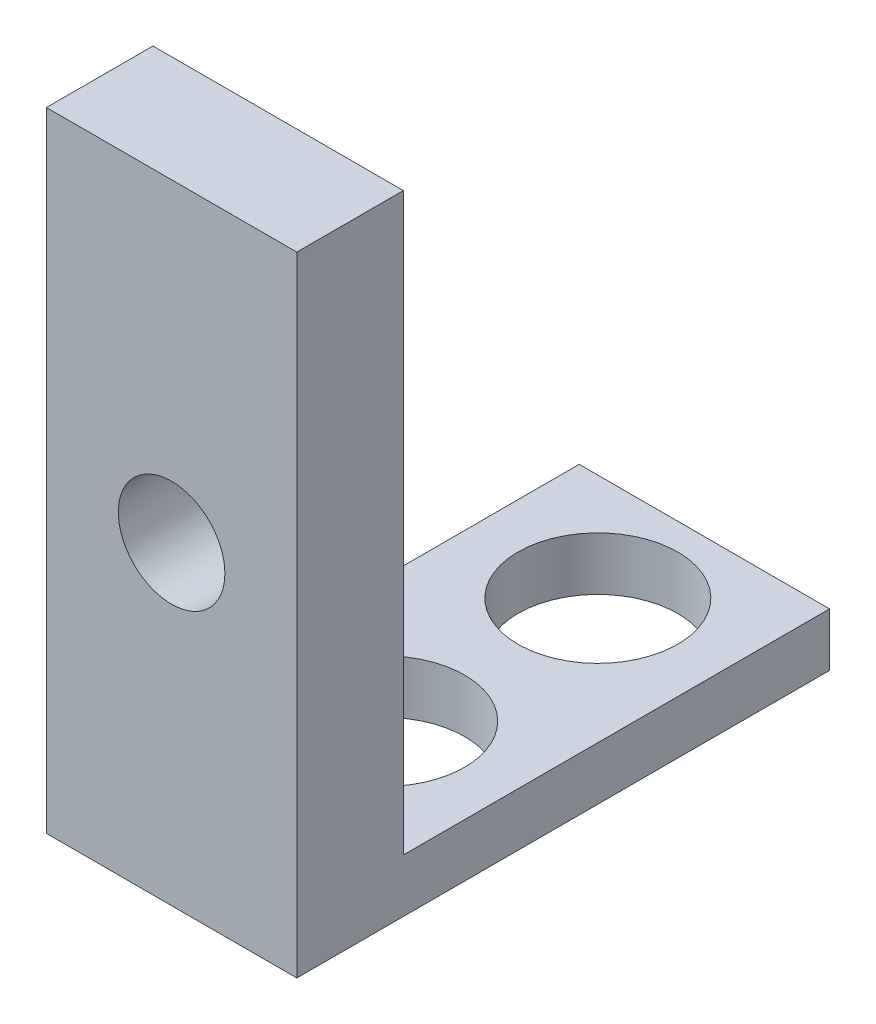
from build123d import *

# Parameters (mm, degrees)
SKETCH1_W           = 4.7
SKETCH1_H           = 11.8
SKETCH1_R           = 1
BOSS_EXTRUDE1_DEPTH = 2
SKETCH2_W           = 4.7
SKETCH2_H           = 1
BOSS_EXTRUDE2_DEPTH = 8
SKETCH3_R           = 1.5
CUT_EXTRUDE1_DEPTH  = 8


with BuildPart() as part:
    # Sketch1 → Boss-Extrude1 (new body)
    with BuildSketch(Plane.XY):
        with Locations((2.35, 5.9)):
            Rectangle(SKETCH1_W, SKETCH1_H)
        with Locations((2.35, 5.9)):
            Circle(SKETCH1_R, mode=Mode.SUBTRACT)
    extrude(amount=BOSS_EXTRUDE1_DEPTH)

    # Sketch2 → Boss-Extrude2 (add)
    with BuildSketch(Plane(origin=(0, 0, 0), x_dir=(-1, 0, 0), z_dir=(0, 0, -1))):
        with Locations((-2.35, 0.5)):
            Rectangle(SKETCH2_W, SKETCH2_H)
    extrude(amount=BOSS_EXTRUDE2_DEPTH)

    # Sketch3 → Cut-Extrude1 (cut)
    with BuildSketch(Plane(origin=(0, 1, 0), x_dir=(1, 0, 0), z_dir=(0, 1, 0))):
        with Locations((2.35, 2)):
            Circle(SKETCH3_R)
        with Locations((2.35, 6)):
            Circle(SKETCH3_R)
    extrude(amount=-CUT_EXTRUDE1_DEPTH, mode=Mode.SUBTRACT)


solid = part.part
